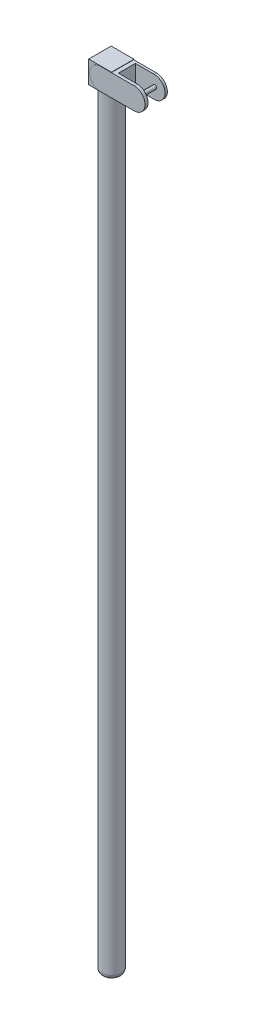
from build123d import *

# Parameters (mm, degrees)
IZIM1_R                     = 2.187508585
Y_KSEKLIK_EKSTR_ZYON1_DEPTH = 177
RADYUS1_R                   = 1
IZIM2_W                     = 5.115236905
IZIM2_H                     = 5.042987796
Y_KSEKLIK_EKSTR_ZYON2_DEPTH = 5
Y_KSEKLIK_EKSTR_ZYON3_DEPTH = 2.5
IZIM4_W                     = 9.955982426
IZIM4_H                     = 3.788849983
KES_EKSTR_ZYON1_DEPTH       = 5
IZIM5_R                     = 0.420224292
Y_KSEKLIK_EKSTR_ZYON4_DEPTH = 5


with BuildPart() as part:
    # Çizim1 → Yükseklik-Ekstrüzyon1 (new body)
    with BuildSketch(Plane(origin=(0, 0, 0), x_dir=(1, 0, 0), z_dir=(0, 1, 0))):
        Circle(IZIM1_R)
    extrude(amount=Y_KSEKLIK_EKSTR_ZYON1_DEPTH)

    # Radyus1
    radyus1_edges = [part.edges().sort_by_distance(p)[0] for p in [
        (-2.187508585, 0, 0),
    ]]
    fillet(radyus1_edges, radius=RADYUS1_R)

    # Çizim2 → Yükseklik-Ekstrüzyon2 (add)
    with BuildSketch(Plane(origin=(0, 177, 0), x_dir=(1, 0, 0), z_dir=(0, 1, 0))):
        with Locations((-0.108373663, 0.052171697)):
            Rectangle(IZIM2_W, IZIM2_H)
    extrude(amount=-Y_KSEKLIK_EKSTR_ZYON2_DEPTH)

    # Çizim3 → Yükseklik-Ekstrüzyon3 (add, symmetric)
    with BuildSketch(Plane.XY):
        with BuildLine():
            Line((0, 176.935410542), (7.547644812, 176.935410542))
            ThreePointArc((7.547644812, 176.935410542), (9.98246541, 174.500589945), (7.547644812, 172.065769347))
            Line((7.547644812, 172.065769347), (0, 172.065769347))
            ThreePointArc((0, 172.065769347), (-2.434820598, 174.500589945), (0, 176.935410542))
        make_face()
    extrude(amount=Y_KSEKLIK_EKSTR_ZYON3_DEPTH, both=True)

    # Çizim4 → Kes-Ekstrüzyon1 (cut)
    with BuildSketch(Plane(origin=(0, 176.935410542, 0), x_dir=(1, 0, 0), z_dir=(0, 1, 0))):
        with Locations((8.319846031, 0.078445098)):
            Rectangle(IZIM4_W, IZIM4_H)
    extrude(amount=-KES_EKSTR_ZYON1_DEPTH, mode=Mode.SUBTRACT)

    # Çizim5 → Yükseklik-Ekstrüzyon4 (add)
    with BuildSketch(Plane.XY.offset(2.5)):
        with Locations((7.702816728, 174.562062813)):
            Circle(IZIM5_R)
    extrude(amount=-Y_KSEKLIK_EKSTR_ZYON4_DEPTH)


solid = part.part
